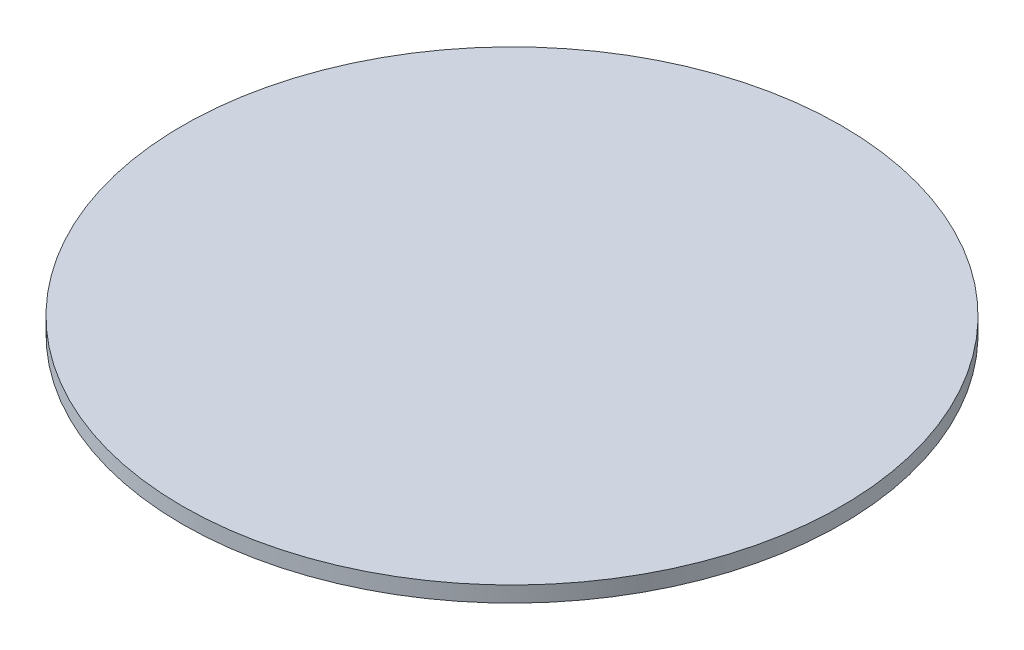
from build123d import *

# Parameters (mm, degrees)
SKETCH1_R           = 105
BOSS_EXTRUDE4_DEPTH = 5


with BuildPart() as part:
    # Sketch1 → Boss-Extrude4 (new body)
    with BuildSketch(Plane(origin=(0, 0, 0), x_dir=(1, 0, 0), z_dir=(0, 1, 0))):
        Circle(SKETCH1_R)
    extrude(amount=BOSS_EXTRUDE4_DEPTH)


solid = part.part
